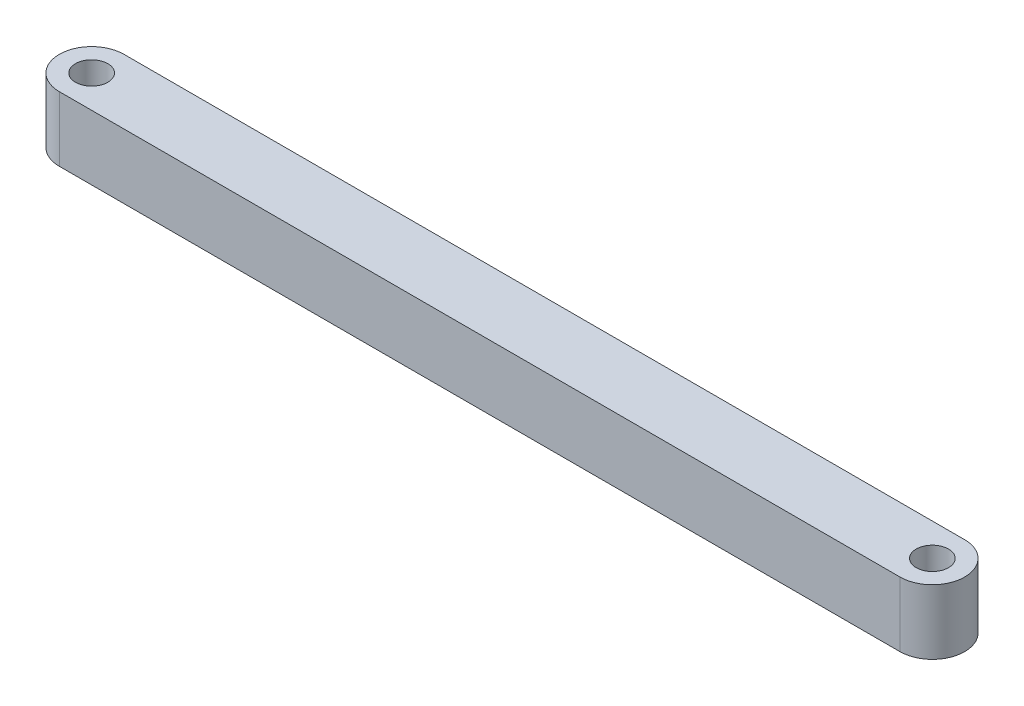
from build123d import *

# Parameters (mm, degrees)
SKETCH2_R           = 2.5
BOSS_EXTRUDE2_DEPTH = 10


with BuildPart() as part:
    # Sketch2 → Boss-Extrude2 (new body)
    with BuildSketch(Plane(origin=(0, 0, 0), x_dir=(1, 0, 0), z_dir=(0, 1, 0))):
        with BuildLine():
            Line((-65, -5), (65, -5))
            ThreePointArc((65, -5), (70, 0), (65, 5))
            Line((65, 5), (-65, 5))
            ThreePointArc((-65, 5), (-70, 0), (-65, -5))
        make_face()
        with Locations((-65, 0)):
            Circle(SKETCH2_R, mode=Mode.SUBTRACT)
        with Locations((65, 0)):
            Circle(SKETCH2_R, mode=Mode.SUBTRACT)
    extrude(amount=BOSS_EXTRUDE2_DEPTH)


solid = part.part
